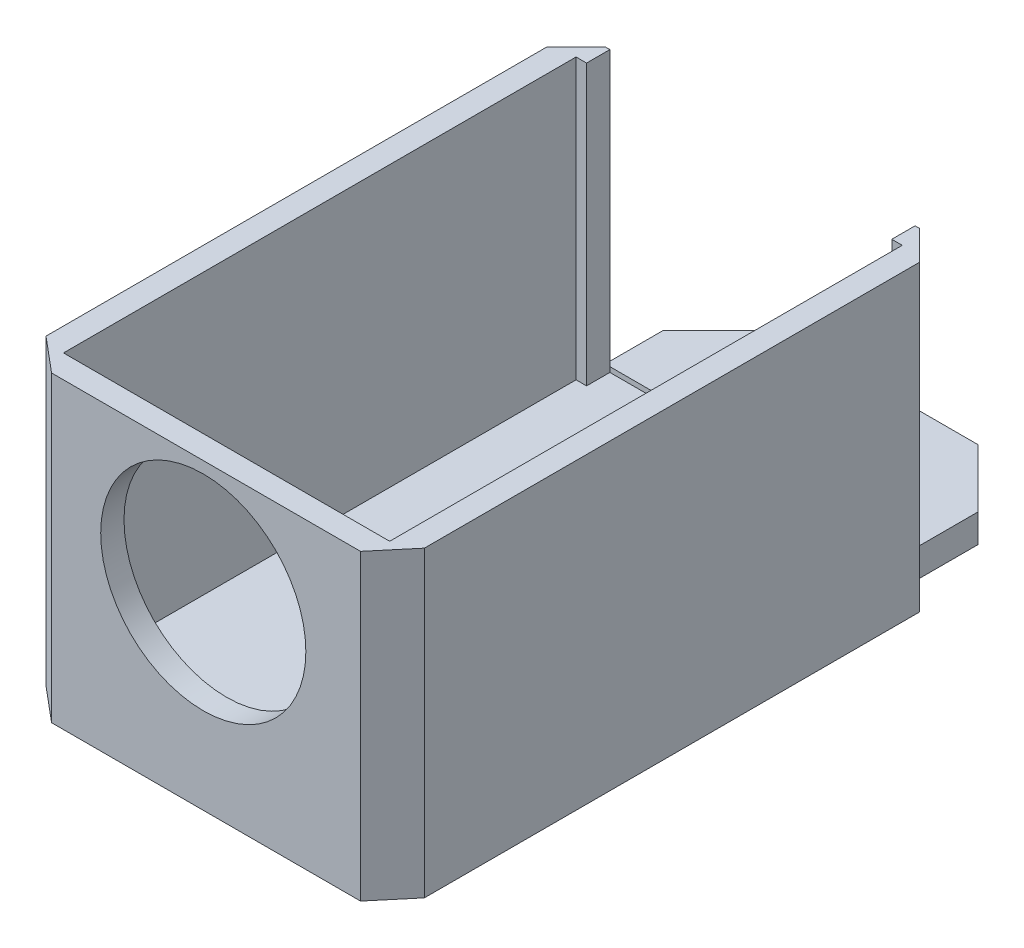
from build123d import *

# Parameters (mm, degrees)
SKETCH1_W             = 32
SKETCH1_H             = 48
BOSS_EXTRUDE1_DEPTH   = 26
SHELL1_T              = -2
SKETCH2_W             = 26.2
SKETCH2_H             = 24
CUT_EXTRUDE1_DEPTH    = 20
CHAMFER1_SIZE         = 2.5
CHAMFER1_SIZE2        = 2.979383981
CHAMFER1_PART_2_SIZE  = 2.5
CHAMFER1_PART_2_SIZE2 = 2.979383981
CHAMFER3_SIZE         = 2.5
SKETCH5_W             = 27
SKETCH5_H             = 2.432389293
BOSS_EXTRUDE3_DEPTH   = 10
CHAMFER4_SIZE         = 5
SKETCH6_R             = 8.805
CUT_EXTRUDE3_DEPTH    = 10


with BuildPart() as part:
    # Sketch1 → Boss-Extrude1 (new body)
    with BuildSketch(Plane(origin=(0, 0, 0), x_dir=(1, 0, 0), z_dir=(0, 1, 0))):
        Rectangle(SKETCH1_W, SKETCH1_H)
    extrude(amount=BOSS_EXTRUDE1_DEPTH)

    # Shell1
    shell1_openings = [part.faces().sort_by_distance(p)[0] for p in [
        (0, 26, 0),
    ]]
    offset(amount=SHELL1_T, openings=shell1_openings, kind=Kind.INTERSECTION)

    # Sketch2 → Cut-Extrude1 (cut)
    with BuildSketch(Plane(origin=(0, 0, -24), x_dir=(-1, 0, 0), z_dir=(0, 0, -1))):
        with Locations((0, 14)):
            Rectangle(SKETCH2_W, SKETCH2_H)
    extrude(amount=-CUT_EXTRUDE1_DEPTH, mode=Mode.SUBTRACT)

    # Chamfer1
    chamfer1_edges = [part.edges().sort_by_distance(p)[0] for p in [
        (16, 13, 24),
    ]]
    chamfer1_side = [part.faces().sort_by_distance(p)[0] for p in [
        (0, 13, 24),
    ]]
    chamfer(chamfer1_edges, length=CHAMFER1_SIZE, length2=CHAMFER1_SIZE2, reference=chamfer1_side[0])

    # Chamfer1 part 2
    chamfer1_part_2_edges = [part.edges().sort_by_distance(p)[0] for p in [
        (-16, 13, 24),
    ]]
    chamfer1_part_2_side = [part.faces().sort_by_distance(p)[0] for p in [
        (-16, 13, 0),
    ]]
    chamfer(chamfer1_part_2_edges, length=CHAMFER1_PART_2_SIZE, length2=CHAMFER1_PART_2_SIZE2, reference=chamfer1_part_2_side[0])

    # Chamfer3
    chamfer3_edges = [part.edges().sort_by_distance(p)[0] for p in [
        (-16, 13, -24),
        (16, 13, -24),
    ]]
    chamfer(chamfer3_edges, length=CHAMFER3_SIZE)

    # Sketch5 → Boss-Extrude3 (add)
    with BuildSketch(Plane(origin=(0, 0, -24), x_dir=(-1, 0, 0), z_dir=(0, 0, -1))):
        with Locations((0, 1.216194646)):
            Rectangle(SKETCH5_W, SKETCH5_H)
    extrude(amount=BOSS_EXTRUDE3_DEPTH)

    # Chamfer4
    chamfer4_edges = [part.edges().sort_by_distance(p)[0] for p in [
        (13.5, 1.216194647, -34),
        (-13.5, 1.216194647, -34),
    ]]
    chamfer(chamfer4_edges, length=CHAMFER4_SIZE)

    # Sketch6 → Cut-Extrude3 (cut)
    with BuildSketch(Plane.XY.offset(24)):
        with Locations((0, 16.205)):
            Circle(SKETCH6_R)
    extrude(amount=-CUT_EXTRUDE3_DEPTH, mode=Mode.SUBTRACT)


solid = part.part
